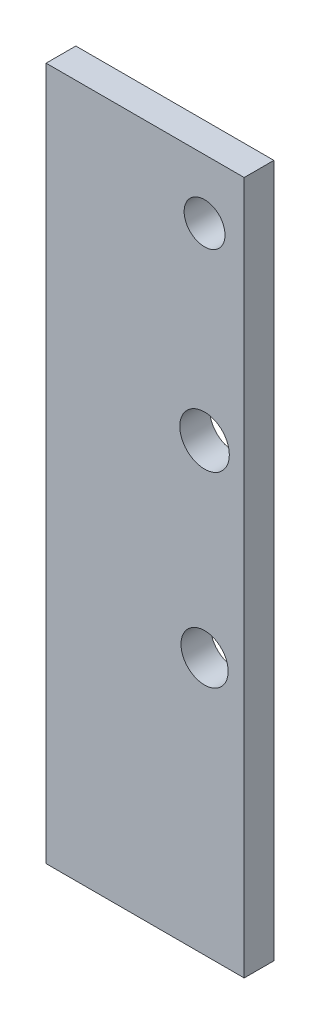
from build123d import *

# Parameters (mm, degrees)
SKETCH1_W           = 100
SKETCH1_H           = 15
BOSS_EXTRUDE1_DEPTH = 350
SKETCH2_R           = 12.5
CUT_EXTRUDE1_DEPTH  = 16
SKETCH3_R           = 10.318452201
SKETCH3_R_2         = 11.907148997
CUT_EXTRUDE2_DEPTH  = 16


with BuildPart() as part:
    # Sketch1 → Boss-Extrude1 (new body)
    with BuildSketch(Plane(origin=(0, 0, 0), x_dir=(1, 0, 0), z_dir=(0, 1, 0))):
        with Locations((50, 7.5)):
            Rectangle(SKETCH1_W, SKETCH1_H)
    extrude(amount=BOSS_EXTRUDE1_DEPTH)

    # Sketch2 → Cut-Extrude1 (cut, through all)
    with BuildSketch(Plane.XY):
        with Locations((80, 225)):
            Circle(SKETCH2_R)
    extrude(amount=-CUT_EXTRUDE1_DEPTH, mode=Mode.SUBTRACT)

    # Sketch3 → Cut-Extrude2 (cut, through all)
    with BuildSketch(Plane.XY):
        with Locations((80, 320)):
            Circle(SKETCH3_R)
        with Locations((80, 130)):
            Circle(SKETCH3_R_2)
    extrude(amount=-CUT_EXTRUDE2_DEPTH, mode=Mode.SUBTRACT)


solid = part.part
